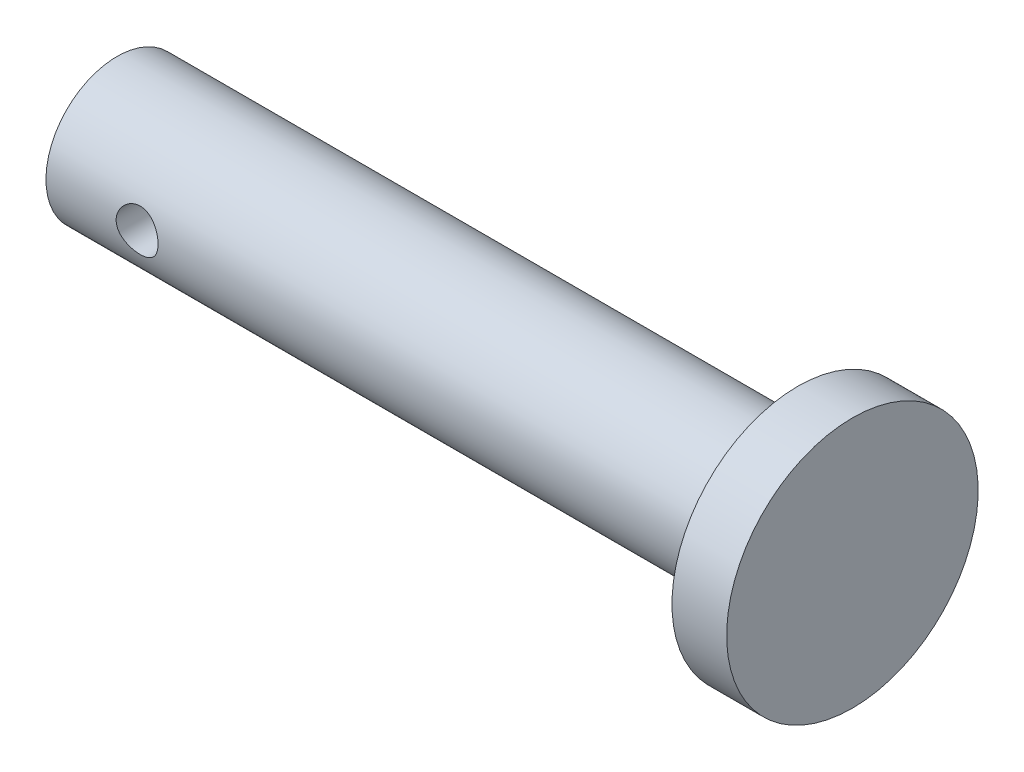
from build123d import *

# Parameters (mm, degrees)
CUT_EXTRUDE1_DEPTH      = 20.472432437
CUT_EXTRUDE1_DEPTH_BACK = 20.472432437
SKETCH2_3_R             = 1.15
SKETCH3_R               = 6.9
BOSS_EXTRUDE1_DEPTH     = 3


with BuildPart() as part:
    # Sketch2 → Revolve2 (revolve)
    with BuildSketch(Plane.XY):
        with BuildLine():
            Line((18.675, 0), (-12.525, 0))
            ThreePointArc((-12.525, 0), (-13.675, -1.15), (-14.825, 0))
            Line((-14.825, 0), (-18.675, 0))
            Line((-18.675, 0), (-18.675, -3.9))
            Line((-18.675, -3.9), (18.675, -3.9))
            Line((18.675, -3.9), (18.675, 0))
        make_face()
    revolve(axis=Axis((-18.675, 0, 0), (1, 0, 0)))

    # Sketch2_3 → Cut-Extrude1 (cut, two sides: drawn at the far end of the back side and taken through both)
    with BuildSketch(Plane.XY.offset(-CUT_EXTRUDE1_DEPTH_BACK)):
        with Locations((-13.675, 0)):
            Circle(SKETCH2_3_R)
    extrude(amount=CUT_EXTRUDE1_DEPTH + CUT_EXTRUDE1_DEPTH_BACK, mode=Mode.SUBTRACT)

    # Sketch3 → Boss-Extrude1 (add)
    with BuildSketch(Plane(origin=(18.675, 0, 0), x_dir=(0, 0, -1), z_dir=(1, 0, 0))):
        Circle(SKETCH3_R)
    extrude(amount=BOSS_EXTRUDE1_DEPTH)


solid = part.part
